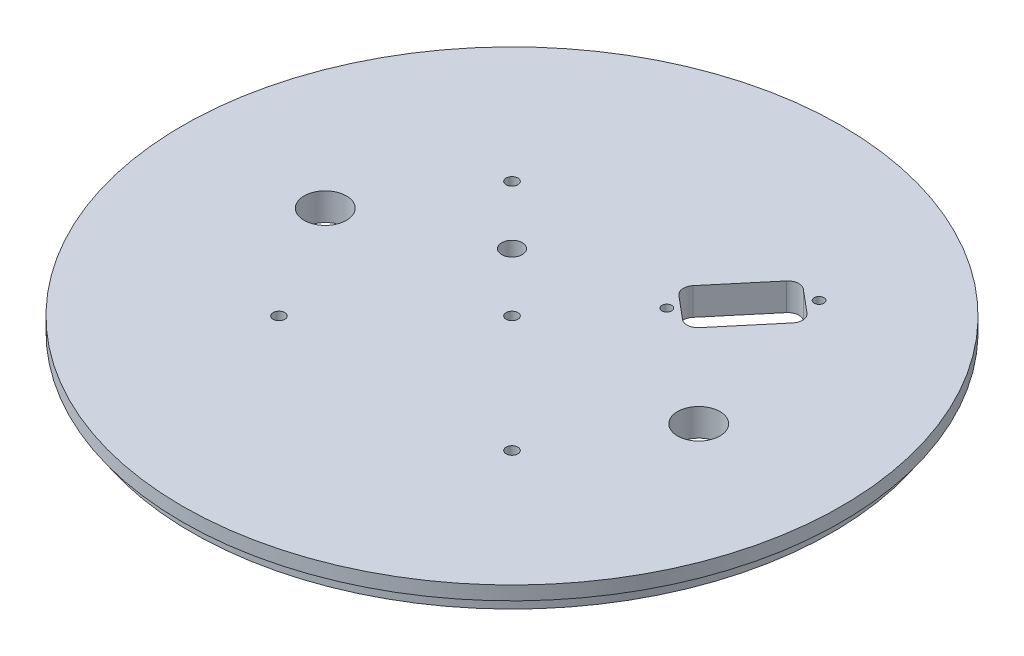
from build123d import *

# Parameters (mm, degrees)
SKETCH1_R                 = 76.2
SKETCH1_R_2               = 4.9022
SKETCH1_R_3               = 1.3589
SKETCH1_R_4               = 2.38125
BOSS_EXTRUDE1_DEPTH       = 6.35
SKETCH2_R                 = 76.2
SKETCH2_R_2               = 74.041
CUT_EXTRUDE1_DEPTH        = 3.175
CUT_EXTRUDE2_START        = -3.175
CUT_EXTRUDE2_DEPTH        = 3.556
TAP_DRILL_FOR_4_40_TAP1_D = 2.2606
CUT_EXTRUDE3_DEPTH        = 7.35


with BuildPart() as part:
    # Sketch1 → Boss-Extrude1 (new body)
    with BuildSketch(Plane(origin=(0, 0, 0), x_dir=(1, 0, 0), z_dir=(0, 1, 0))):
        Circle(SKETCH1_R)
        with Locations((43.18, 0)):
            Circle(SKETCH1_R_2, mode=Mode.SUBTRACT)
        with Locations((-43.18, 0)):
            Circle(SKETCH1_R_2, mode=Mode.SUBTRACT)
        with Locations((-26.940768363, 26.940768363)):
            Circle(SKETCH1_R_3, mode=Mode.SUBTRACT)
        with Locations((26.940768363, -26.940768363)):
            Circle(SKETCH1_R_3, mode=Mode.SUBTRACT)
        with Locations((-13.470384182, 13.470384182)):
            Circle(SKETCH1_R_4, mode=Mode.SUBTRACT)
        with Locations((-26.940768363, -26.940768363)):
            Circle(SKETCH1_R_3, mode=Mode.SUBTRACT)
        Circle(SKETCH1_R_3, mode=Mode.SUBTRACT)
    extrude(amount=BOSS_EXTRUDE1_DEPTH)

    # Sketch2 → Cut-Extrude1 (cut)
    with BuildSketch(Plane.XZ):
        Circle(SKETCH2_R)
        Circle(SKETCH2_R_2, mode=Mode.SUBTRACT)
    extrude(amount=-CUT_EXTRUDE1_DEPTH, mode=Mode.SUBTRACT)

    # Sketch3 → Cut-Extrude2 (cut)
    with BuildSketch(Plane(origin=(0, 6.35, 0), x_dir=(1, 0, 0), z_dir=(0, 1, 0)).offset(CUT_EXTRUDE2_START)):
        with BuildLine():
            Line((3.2385, 34.798), (3.2385, 13.97))
            ThreePointArc((3.2385, 13.97), (0, 10.7315), (-3.2385, 13.97))
            Line((-3.2385, 13.97), (-3.2385, 34.798))
            ThreePointArc((-3.2385, 34.798), (0, 38.0365), (3.2385, 34.798))
        make_face()
        with BuildLine():
            Line((3.2385, -34.798), (3.2385, -13.97))
            ThreePointArc((3.2385, -13.97), (0, -10.7315), (-3.2385, -13.97))
            Line((-3.2385, -13.97), (-3.2385, -34.798))
            ThreePointArc((-3.2385, -34.798), (0, -38.0365), (3.2385, -34.798))
        make_face()
    extrude(amount=-CUT_EXTRUDE2_DEPTH, mode=Mode.SUBTRACT)

    # Tap Drill for #4-40 Tap1 (through all)
    with Locations(Plane(origin=(0, 6.35, 0), x_dir=(1, 0, 0), z_dir=(0, 1, 0))):
        with Locations((16.326805286, 19.457528855), (32.396495553, 38.608639962)):
            Hole(TAP_DRILL_FOR_4_40_TAP1_D / 2)

    # Sketch4 → Cut-Extrude3 (cut, through all)
    with BuildSketch(Plane(origin=(0, 6.35, 0), x_dir=(1, 0, 0), z_dir=(0, 1, 0))):
        with BuildLine():
            Line((15.169451366, 23.412825166), (20.422984157, 19.004587739))
            ThreePointArc((20.422984157, 19.004587739), (22.277040272, 18.420006091), (24.001417571, 19.317660095))
            Line((24.001417571, 19.317660095), (33.866921829, 31.074910238))
            ThreePointArc((33.866921829, 31.074910238), (34.451503477, 32.928966353), (33.553849472, 34.653343652))
            Line((33.553849472, 34.653343652), (28.300316681, 39.061581079))
            ThreePointArc((28.300316681, 39.061581079), (26.446260566, 39.646162727), (24.721883267, 38.748508722))
            Line((24.721883267, 38.748508722), (14.856379009, 26.99125858))
            ThreePointArc((14.856379009, 26.99125858), (14.271797362, 25.137202465), (15.169451366, 23.412825166))
        make_face()
    extrude(amount=-CUT_EXTRUDE3_DEPTH, mode=Mode.SUBTRACT)


solid = part.part
